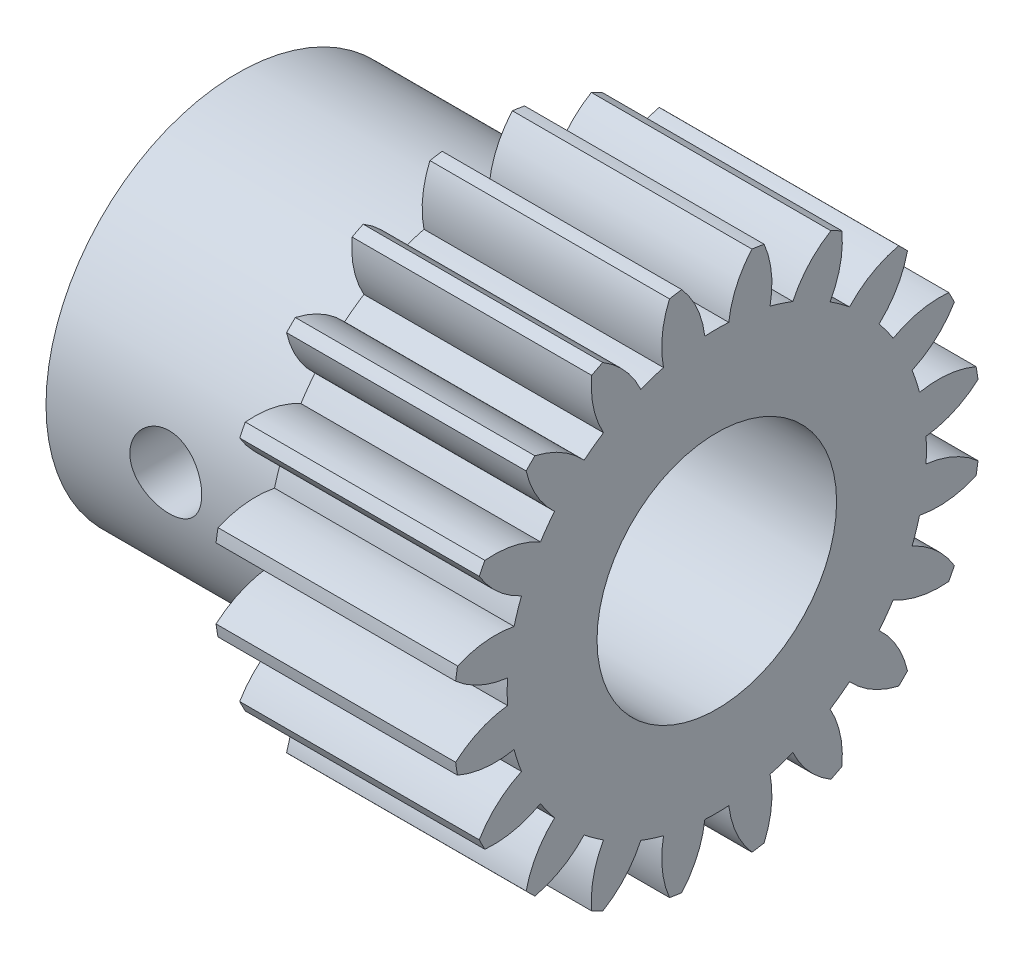
from build123d import *

# Parameters (mm, degrees)
BASPROSKE_W              = 10
BASPROSKE_H              = 11
TOOTHCUT_DEPTH           = 19.493242009
TEETHCUTS_COUNT          = 20
TEETHCUTS_ANGLE          = 342
HUBNEAONESKE_R           = 8
HUBNEARONE_DEPTH         = 10.0000508
BORSKE_R                 = 5
BORE_DEPTH               = 20.0000508
SKETCH_1_R               = 1.5
CUT_EXTRUDE_1_DEPTH      = 9
CUT_EXTRUDE_1_DEPTH_BACK = 1


with BuildPart() as part:
    # BasProSke → Base-Revolve (revolve)
    with BuildSketch(Plane(origin=(0, 0, 0), x_dir=(1, 0, 0), z_dir=(0, 1, 0)), mode=Mode.PRIVATE) as base_revolve_sk:
        with Locations((5, 5.5)):
            Rectangle(BASPROSKE_W, BASPROSKE_H)
    revolve(base_revolve_sk.sketch.rotate(Axis((-10, 0, 0), (1, 0, 0)), 180), axis=Axis((-10, 0, 0), (1, 0, 0)))

    # TooCutSke → ToothCut (cut, through all)
    with BuildSketch(Plane(origin=(0, 0, 0), x_dir=(0, 0, -1), z_dir=(1, 0, 0))):
        with BuildLine():
            ThreePointArc((0.499924007, 8.734705318), (0, 8.749), (-0.499924007, 8.734705318))
            ThreePointArc((-0.499924007, 8.734705318), (-0.824302243, 9.905497836), (-1.485192705, 10.924909509))
            ThreePointArc((-1.485192705, 10.924909509), (0, 11.0254), (1.485192705, 10.924909509))
            ThreePointArc((1.485192705, 10.924909509), (0.824302243, 9.905497836), (0.499924007, 8.734705318))
        make_face()
    toothcut = extrude(amount=TOOTHCUT_DEPTH, mode=Mode.SUBTRACT)

    # TeethCuts: ToothCut ×20 about axis
    teethcuts_axis = Axis((-10, 0, 0), (1, 0, 0))
    for i in range(1, TEETHCUTS_COUNT):
        add(toothcut.rotate(teethcuts_axis, i * TEETHCUTS_ANGLE / (TEETHCUTS_COUNT - 1)), mode=Mode.SUBTRACT)

    # HubNeaOneSke → HubNearOne (add)
    with BuildSketch(Plane.ZY):
        with Locations(Location((0, 0, 0), (0, 0, 180))):
            Circle(HUBNEAONESKE_R)
    extrude(amount=HUBNEARONE_DEPTH)

    # BorSke → Bore (cut, symmetric)
    with BuildSketch(Plane(origin=(0, 0, 0), x_dir=(0, 0, -1), z_dir=(1, 0, 0))):
        with Locations(Location((0, 0, 0), (0, 0, 180))):
            Circle(BORSKE_R)
    extrude(amount=BORE_DEPTH, both=True, mode=Mode.SUBTRACT)

    # 草图1 → 切除-拉伸1 (cut, two sides)
    with BuildSketch(Plane.XY) as cut_extrude_1_sk:
        with Locations(Location((-5.0000508, 0, 0), (0, 0, 180.000000001))):
            Circle(SKETCH_1_R)
    extrude(amount=CUT_EXTRUDE_1_DEPTH, mode=Mode.SUBTRACT)
    extrude(cut_extrude_1_sk.sketch, amount=-CUT_EXTRUDE_1_DEPTH_BACK, mode=Mode.SUBTRACT)


solid = part.part
